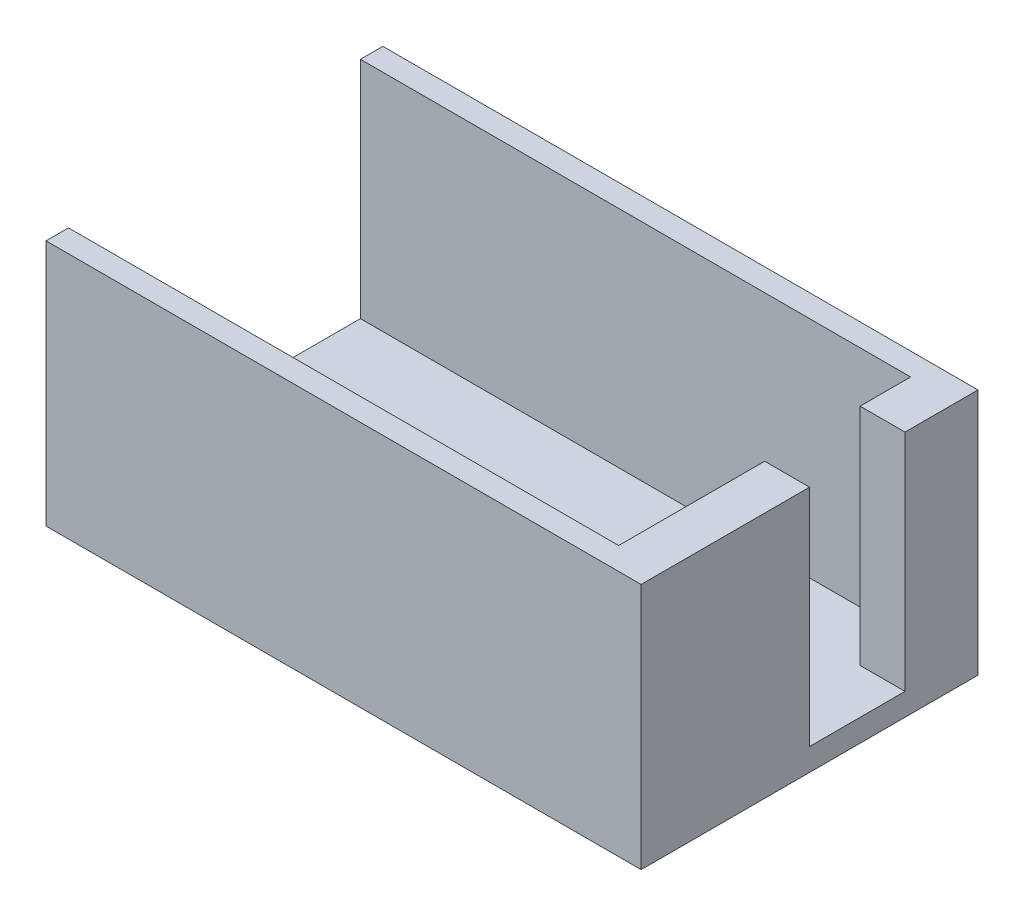
from build123d import *

# Parameters (mm, degrees)
SKETCH1_W           = 53
SKETCH1_H           = 30
BOSS_EXTRUDE1_DEPTH = 2
BOSS_EXTRUDE2_DEPTH = 20


with BuildPart() as part:
    # Sketch1 → Boss-Extrude1 (new body)
    with BuildSketch(Plane(origin=(0, 0, 0), x_dir=(1, 0, 0), z_dir=(0, 1, 0))):
        with Locations((26.5, -15)):
            Rectangle(SKETCH1_W, SKETCH1_H)
    extrude(amount=BOSS_EXTRUDE1_DEPTH)

    # Sketch2 → Boss-Extrude2 (add)
    with BuildSketch(Plane(origin=(0, 2, 0), x_dir=(1, 0, 0), z_dir=(0, 1, 0))):
        Polygon((0, -28), (49, -28), (49, -15), (53, -15), (53, -30), (0, -30), align=None)
        Polygon((49, -2), (0, -2), (0, 0), (53, 0), (53, -6.5), (49, -6.5), align=None)
    extrude(amount=BOSS_EXTRUDE2_DEPTH)


solid = part.part
